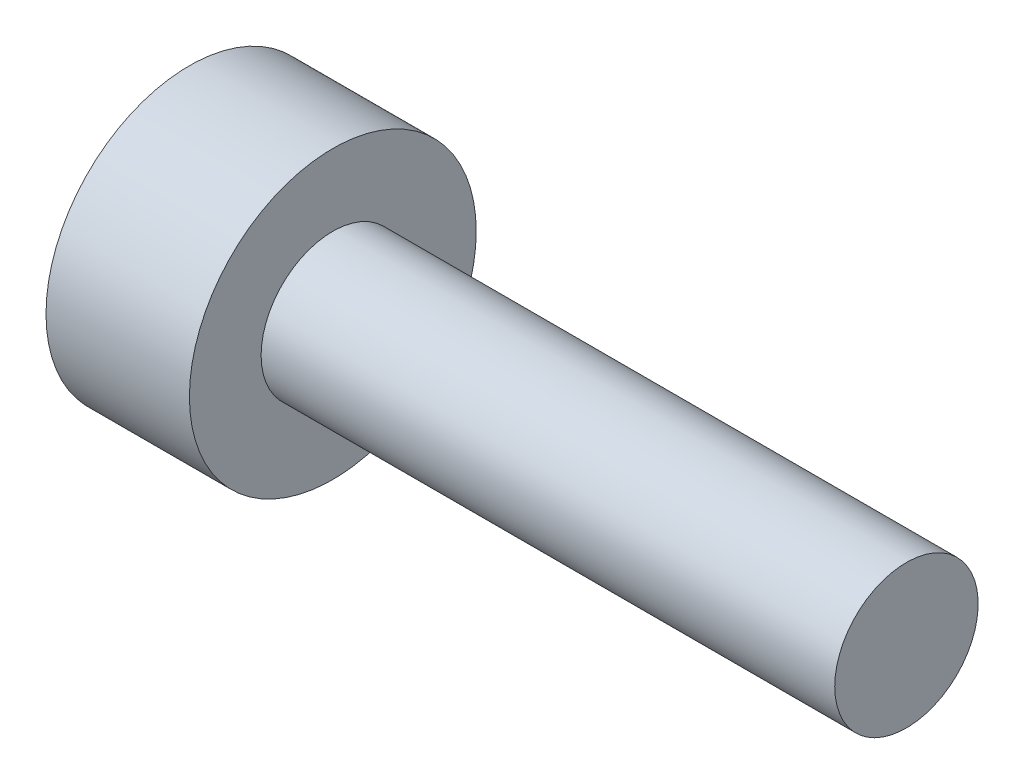
from build123d import *

# Parameters (mm, degrees)
CUT_EXTRUDE_1_DEPTH = 1.5


with BuildPart() as part:
    # Эскиз1 → Повернуть1 (revolve)
    with BuildSketch(Plane.XY):
        Polygon((0, 0), (0, 2), (2, 2), (2, 1), (10, 1), (10, 0), align=None)
    revolve(axis=Axis((0, 0, 0), (1, 0, 0)))

    # Эскиз2 → Вырез-Вытянуть1 (cut)
    with BuildSketch(Plane.ZY):
        Polygon((0.866025404, 0), (0.433012702, 0.75), (-0.433012702, 0.75), (-0.866025404, 0), (-0.433012702, -0.75), (0.433012702, -0.75), align=None)
    extrude(amount=-CUT_EXTRUDE_1_DEPTH, mode=Mode.SUBTRACT)


solid = part.part
